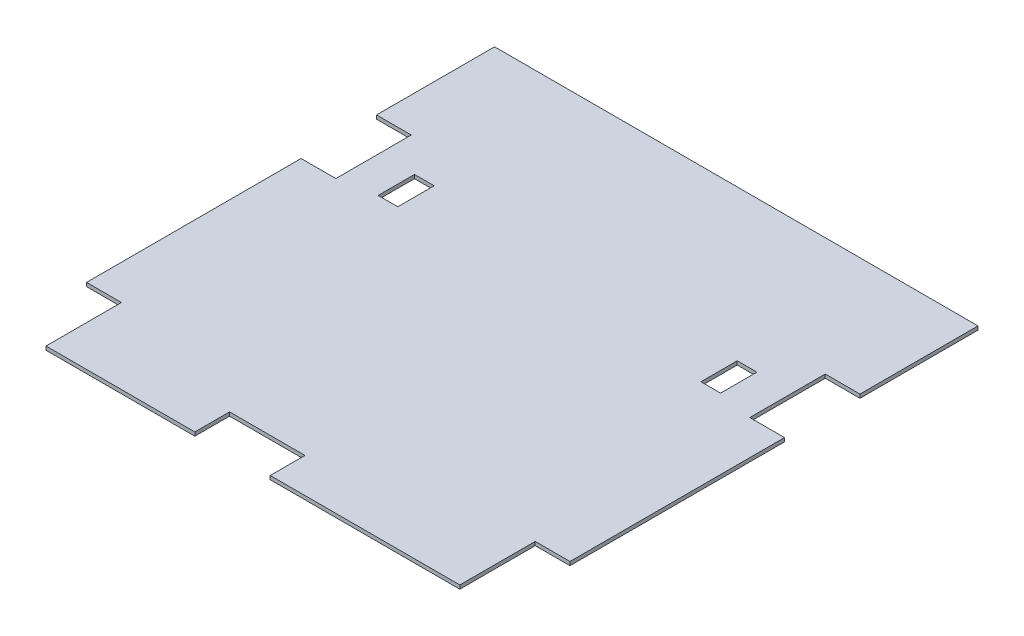
from build123d import *

# Parameters (mm, degrees)
SKETCH1_W           = 416.08
SKETCH1_H           = 416.08
BOSS_EXTRUDE1_DEPTH = 3.175
SKETCH4_W           = 16.914306981
SKETCH4_H           = 31.258998707
SKETCH4_W_2         = 29.9
SKETCH4_H_2         = 64.9
SKETCH4_W_3         = 64.9
SKETCH4_H_3         = 29.9
SKETCH4_W_4         = 30
CUT_EXTRUDE3_DEPTH  = 4.175


with BuildPart() as part:
    # Sketch1 → Boss-Extrude1 (new body)
    with BuildSketch(Plane(origin=(0, 0, 0), x_dir=(1, 0, 0), z_dir=(0, 1, 0))):
        with Locations((208.04, 208.04)):
            Rectangle(SKETCH1_W, SKETCH1_H)
    extrude(amount=BOSS_EXTRUDE1_DEPTH)

    # Sketch4 → Cut-Extrude3 (cut, through all)
    with BuildSketch(Plane.XZ):
        with Locations((69.139038516, -270.834733378)):
            Rectangle(SKETCH4_W, SKETCH4_H)
        with Locations((346.940961485, -270.834733378)):
            Rectangle(SKETCH4_W, SKETCH4_H)
        with Locations((401.13, -32.45)):
            Rectangle(SKETCH4_W_2, SKETCH4_H_2)
        with Locations((190.54, -14.95)):
            Rectangle(SKETCH4_W_3, SKETCH4_H_3)
        with Locations((15, -32.45)):
            Rectangle(SKETCH4_W_4, SKETCH4_H_2)
        with Locations((14.95, -282.03)):
            Rectangle(SKETCH4_W_2, SKETCH4_H_2)
        with Locations((401.13, -282.03)):
            Rectangle(SKETCH4_W_2, SKETCH4_H_2)
    extrude(amount=-CUT_EXTRUDE3_DEPTH, mode=Mode.SUBTRACT)


solid = part.part
